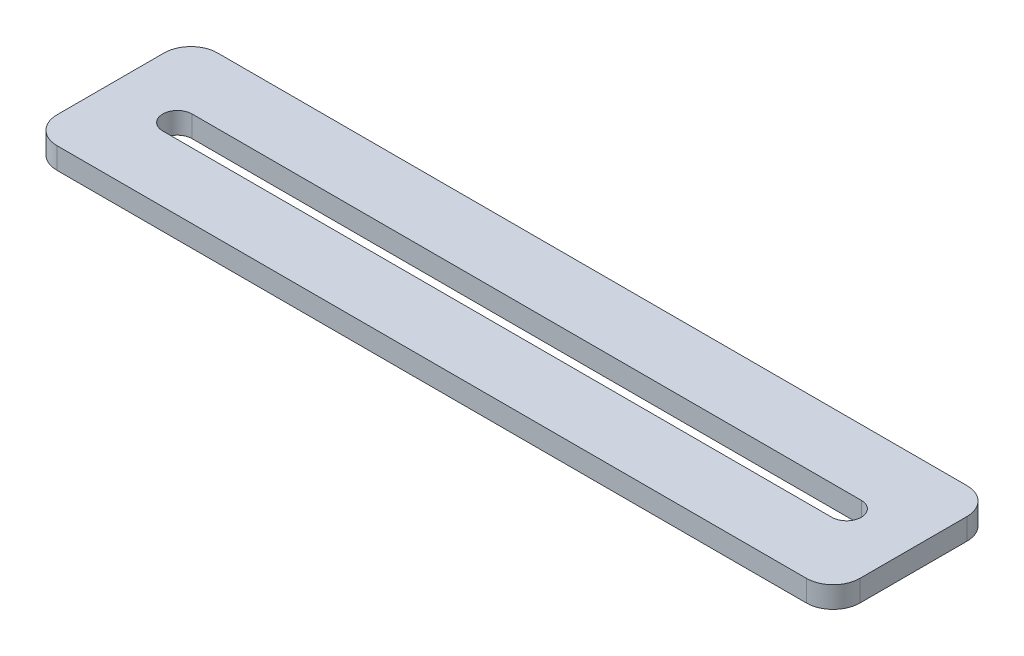
from build123d import *

# Parameters (mm, degrees)
SKETCH1_W           = 150
SKETCH1_H           = 30
BOSS_EXTRUDE1_DEPTH = 4
FILLET1_R           = 5


with BuildPart() as part:
    # Sketch1 → Boss-Extrude1 (new body)
    with BuildSketch(Plane(origin=(0, 0, 0), x_dir=(1, 0, 0), z_dir=(0, 1, 0))):
        Rectangle(SKETCH1_W, SKETCH1_H)
        with BuildLine():
            Line((-62.5, 2.75), (62.5, 2.75))
            ThreePointArc((62.5, 2.75), (65.25, 0), (62.5, -2.75))
            Line((62.5, -2.75), (-62.5, -2.75))
            ThreePointArc((-62.5, -2.75), (-65.25, 0), (-62.5, 2.75))
        make_face(mode=Mode.SUBTRACT)
    extrude(amount=BOSS_EXTRUDE1_DEPTH)

    # Fillet1
    fillet1_edges = [part.edges().sort_by_distance(p)[0] for p in [
        (75, 2, 15),
        (-75, 2, 15),
        (-75, 2, -15),
        (75, 2, -15),
    ]]
    fillet(fillet1_edges, radius=FILLET1_R)


solid = part.part
